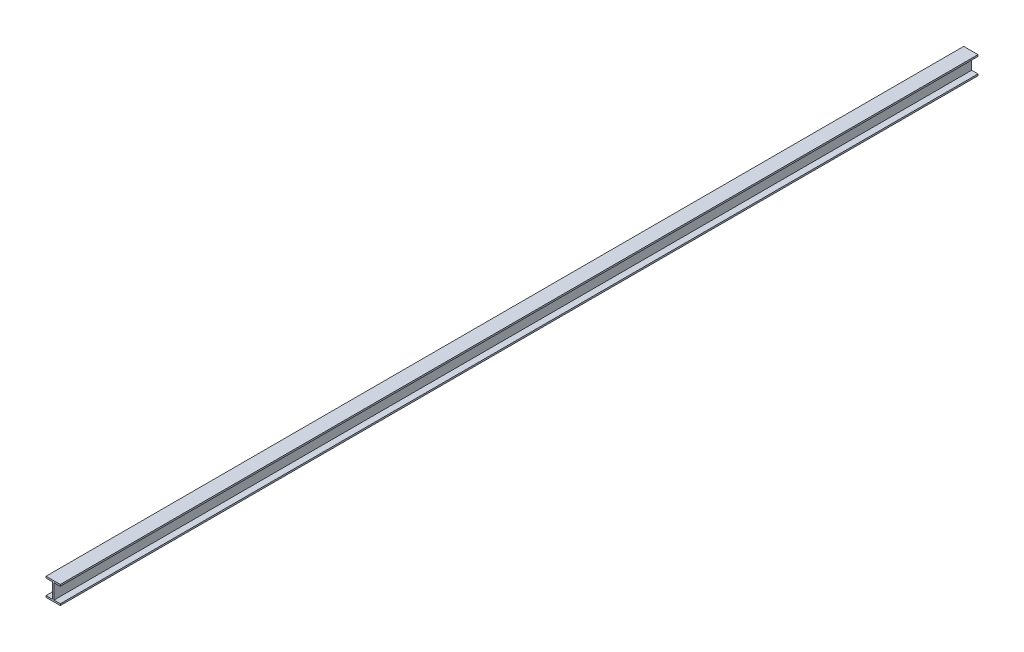
from build123d import *

# Parameters (mm, degrees)
BOSS_EXTRUDE1_DEPTH = 18000


with BuildPart() as part:
    # Sketch1 → Boss-Extrude1 (new body)
    with BuildSketch(Plane.XY):
        Polygon((156, -328), (280, -328), (280, -360), (0, -360), (0, -328), (124, -328), (124, -32), (0, -32), (0, 0), (280, 0), (280, -32), (156, -32), align=None)
    extrude(amount=BOSS_EXTRUDE1_DEPTH)


solid = part.part
